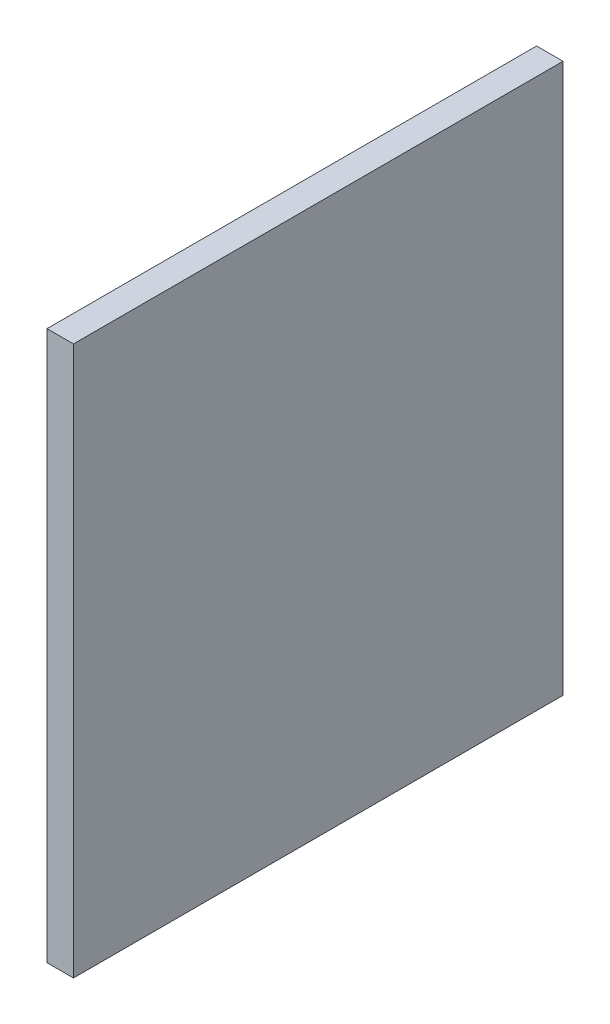
from build123d import *

# Parameters (mm, degrees)
SKETCH1_W           = 296
SKETCH1_H           = 332
BOSS_EXTRUDE1_DEPTH = 16


with BuildPart() as part:
    # Sketch1 → Boss-Extrude1 (new body)
    with BuildSketch(Plane(origin=(0, 0, 0), x_dir=(0, 0, -1), z_dir=(1, 0, 0))):
        Rectangle(SKETCH1_W, SKETCH1_H)
    extrude(amount=BOSS_EXTRUDE1_DEPTH)


solid = part.part
